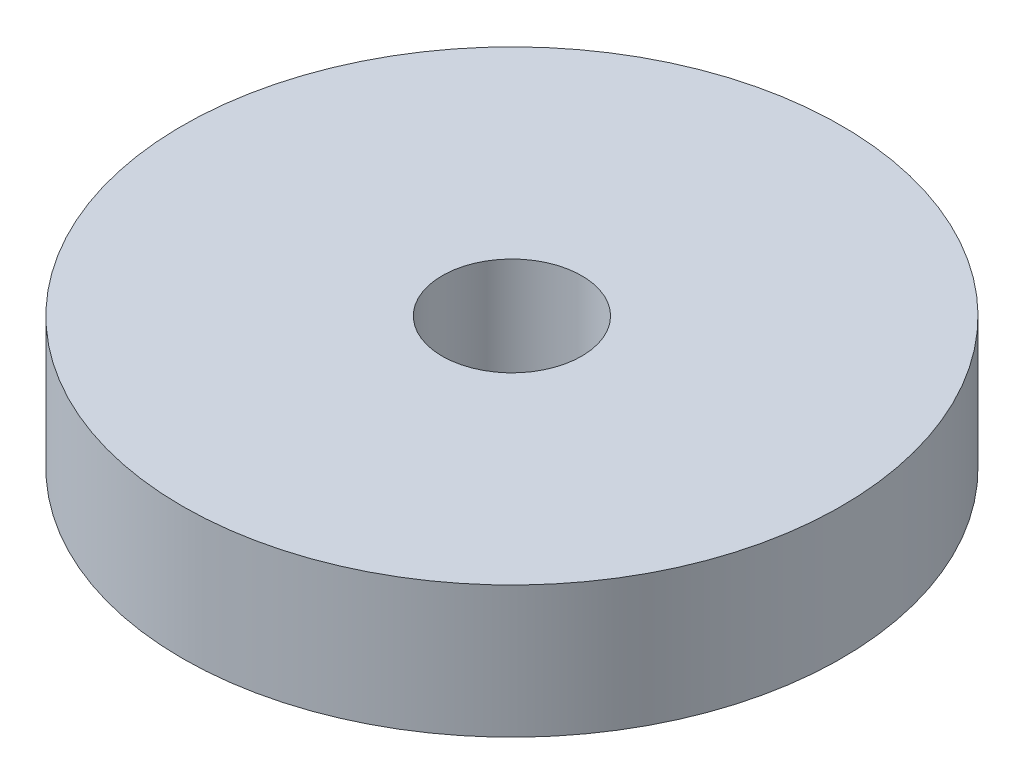
from build123d import *

# Parameters (mm, degrees)
SKETCH1_R           = 29.99994
BOSS_EXTRUDE1_DEPTH = 12.0000014
SKETCH2_R           = 6.35
CUT_EXTRUDE1_DEPTH  = 12.0000014


with BuildPart() as part:
    # Sketch1 → Boss-Extrude1 (new body)
    with BuildSketch(Plane(origin=(0, 0, 0), x_dir=(1, 0, 0), z_dir=(0, 1, 0))):
        Circle(SKETCH1_R)
    extrude(amount=BOSS_EXTRUDE1_DEPTH)

    # Sketch2 → Cut-Extrude1 (cut)
    with BuildSketch(Plane(origin=(0, 12.0000014, 0), x_dir=(1, 0, 0), z_dir=(0, 1, 0))):
        Circle(SKETCH2_R)
    extrude(amount=-CUT_EXTRUDE1_DEPTH, mode=Mode.SUBTRACT)


solid = part.part
